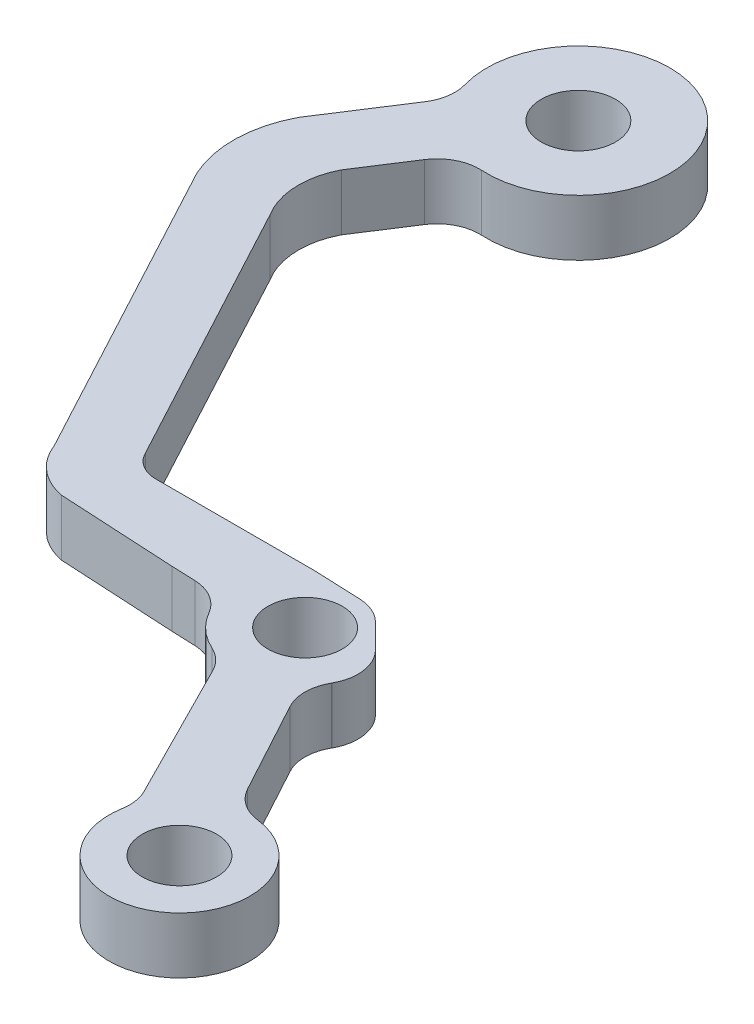
from build123d import *

# Parameters (mm, degrees)
SKETCH1_R           = 2.6375
BOSS_EXTRUDE1_DEPTH = 4


with BuildPart() as part:
    # Sketch1 → Boss-Extrude1 (new body)
    with BuildSketch(Plane(origin=(0, 4, 0), x_dir=(1, 0, 0), z_dir=(0, 1, 0))):
        with BuildLine():
            Line((80.422342857, 54.050517259), (76.853623233, 60.632336961))
            ThreePointArc((76.853623233, 60.632336961), (76.491061204, 62.093363418), (76.883808504, 63.546566463))
            ThreePointArc((76.883808504, 63.546566463), (76.887801931, 63.553594024), (76.891783993, 63.560628031))
            ThreePointArc((76.891783993, 63.560628031), (77.252393533, 65.441834253), (76.401227258, 67.157786484))
            Line((76.401227258, 67.157786484), (74.710106586, 68.848907157))
            ThreePointArc((74.710106586, 68.848907157), (73.793959033, 69.474868842), (72.712949954, 69.725016274))
            Line((72.712949954, 69.725016274), (69.341583584, 69.864669723))
            Line((69.341583584, 69.864669723), (58.04793187, 69.864669723))
            ThreePointArc((58.04793187, 69.864669723), (56.905384642, 70.210123831), (56.115987655, 71.105447853))
            Line((56.115987655, 71.105447853), (45.913475043, 90.139986308))
            ThreePointArc((45.913475043, 90.139986308), (45.078544808, 92.769966676), (45.661998303, 95.466907026))
            Line((45.661998303, 95.466907026), (47.984386737, 99.06049755))
            ThreePointArc((47.984386737, 99.06049755), (49.146460916, 100.107430356), (50.677561656, 100.427141511))
            ThreePointArc((50.677561656, 100.427141511), (55.107636105, 111.997063252), (44.809847991, 105.109087593))
            ThreePointArc((44.809847991, 105.109087593), (44.89620964, 103.838561027), (44.447757125, 102.646677462))
            Line((44.447757125, 102.646677462), (40.917682236, 97.184351056))
            ThreePointArc((40.917682236, 97.184351056), (40.000914232, 93.684113367), (40.729811239, 90.139986308))
            Line((40.729811239, 90.139986308), (52.448751423, 68.276291936))
            ThreePointArc((52.448751423, 68.276291936), (53.733769558, 66.46917356), (55.737555004, 65.519546097))
            Line((55.737555004, 65.519546097), (64.043852088, 65.068697747))
            Line((64.043852088, 65.068697747), (65.737001521, 65.002354827))
            ThreePointArc((65.737001521, 65.002354827), (67.167212394, 64.574619561), (68.214209712, 63.510543803))
            ThreePointArc((68.214209712, 63.510543803), (69.182612076, 62.314016036), (70.4690978, 61.468772687))
            ThreePointArc((70.4690978, 61.468772687), (71.304443417, 60.902477838), (71.904734595, 60.091217919))
            Line((71.904734595, 60.091217919), (76.886572185, 50.235843556))
            ThreePointArc((76.886572185, 50.235843556), (77.175676431, 49.329685255), (77.166582589, 48.378569367))
            ThreePointArc((77.166582589, 48.378569367), (85.084005766, 43.530139369), (82.698094563, 52.502334805))
            ThreePointArc((82.698094563, 52.502334805), (81.37218956, 53.000032473), (80.422342857, 54.050517259))
        make_face()
        with Locations((51.053576092, 106.916256485)):
            Circle(SKETCH1_R, mode=Mode.SUBTRACT)
        with Locations((82.095552315, 47.538773298)):
            Circle(SKETCH1_R, mode=Mode.SUBTRACT)
        with Locations((72.538655529, 66.020358214)):
            Circle(SKETCH1_R, mode=Mode.SUBTRACT)
    extrude(amount=-BOSS_EXTRUDE1_DEPTH)


solid = part.part
